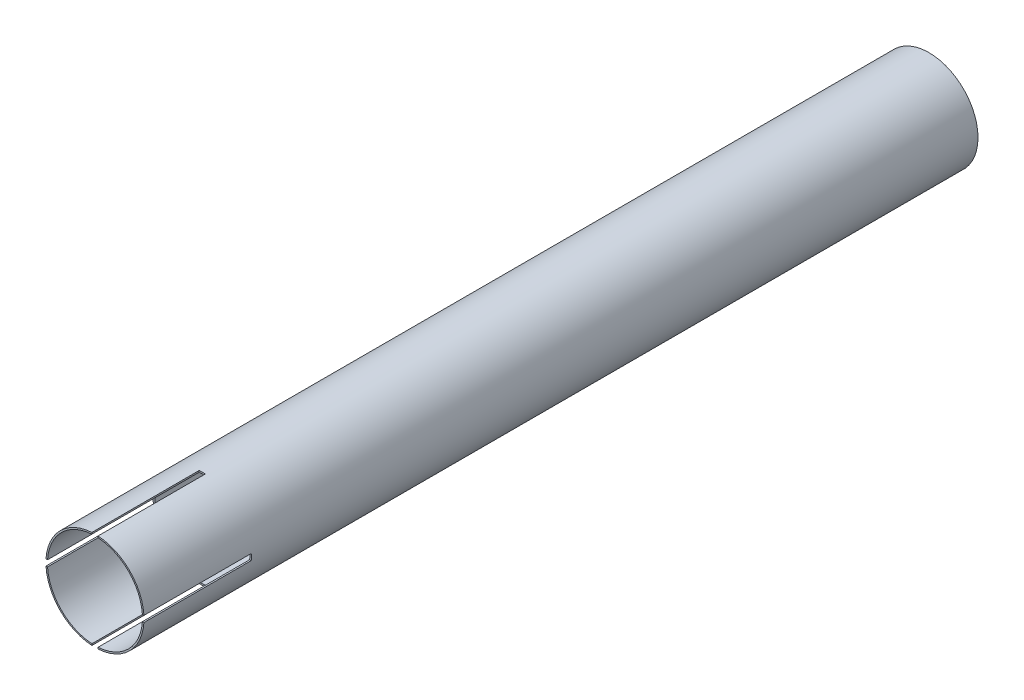
from build123d import *

# Parameters (mm, degrees)
SKETCH1_R               = 50.8
SKETCH1_R_2             = 49.2125
BOSS_EXTRUDE1_DEPTH     = 863.6
SKETCH2_W               = 6.35
SKETCH2_H               = 111.125
CUT_EXTRUDE1_DEPTH      = 51.8
CUT_EXTRUDE1_DEPTH_BACK = 51.8
SKETCH3_W               = 111.125
SKETCH3_H               = 6.35
CUT_EXTRUDE2_DEPTH      = 51.8
CUT_EXTRUDE2_DEPTH_BACK = 51.8


with BuildPart() as part:
    # Sketch1 → Boss-Extrude1 (new body)
    with BuildSketch(Plane.XY):
        Circle(SKETCH1_R)
        Circle(SKETCH1_R_2, mode=Mode.SUBTRACT)
    extrude(amount=BOSS_EXTRUDE1_DEPTH)

    # Sketch2 → Cut-Extrude1 (cut, two sides)
    with BuildSketch(Plane(origin=(0, 0, 0), x_dir=(1, 0, 0), z_dir=(0, 1, 0))) as cut_extrude1_sk:
        with Locations((0, -808.0375)):
            Rectangle(SKETCH2_W, SKETCH2_H)
    extrude(amount=CUT_EXTRUDE1_DEPTH, mode=Mode.SUBTRACT)
    extrude(cut_extrude1_sk.sketch, amount=-CUT_EXTRUDE1_DEPTH_BACK, mode=Mode.SUBTRACT)

    # Sketch3 → Cut-Extrude2 (cut, two sides)
    with BuildSketch(Plane(origin=(0, 0, 0), x_dir=(0, 0, -1), z_dir=(1, 0, 0))) as cut_extrude2_sk:
        with Locations((-808.0375, 0)):
            Rectangle(SKETCH3_W, SKETCH3_H)
    extrude(amount=CUT_EXTRUDE2_DEPTH, mode=Mode.SUBTRACT)
    extrude(cut_extrude2_sk.sketch, amount=-CUT_EXTRUDE2_DEPTH_BACK, mode=Mode.SUBTRACT)


solid = part.part
